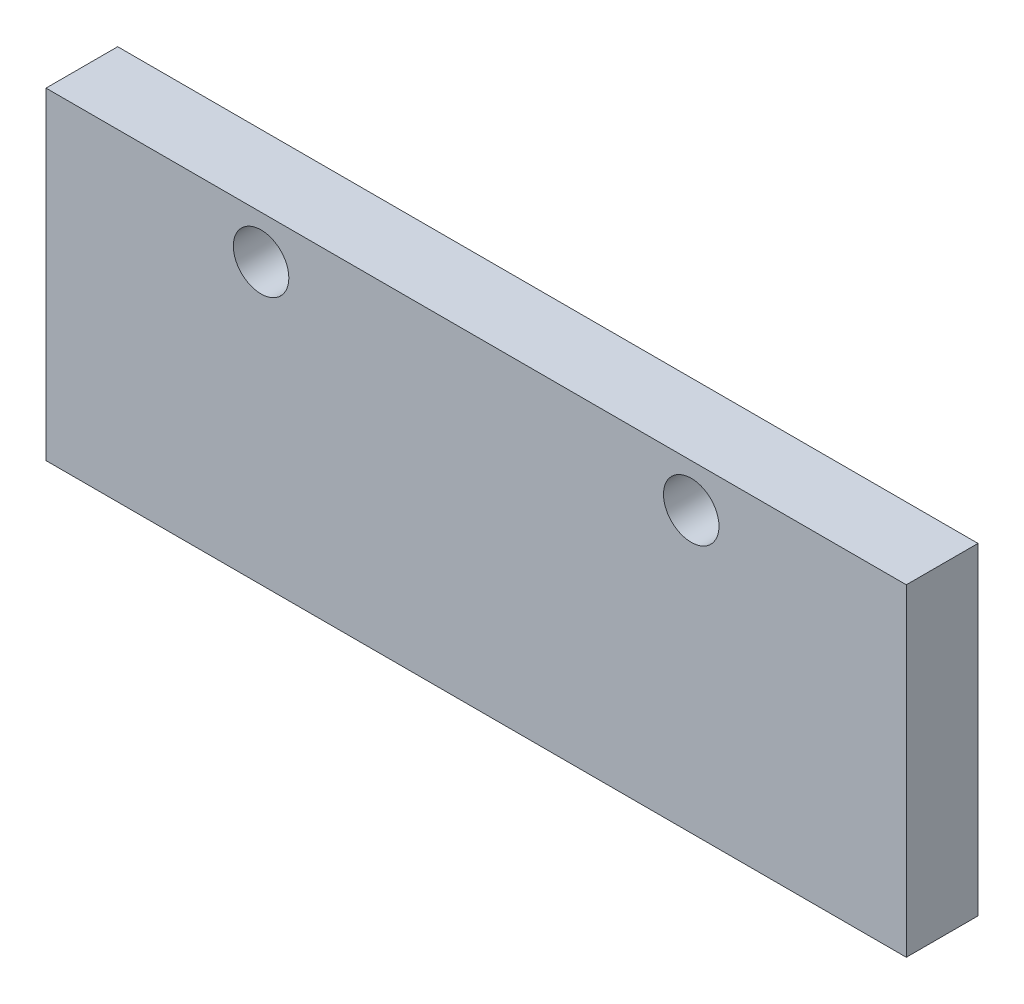
from build123d import *

# Parameters (mm, degrees)
SKETCH1_W                        = 76.2
SKETCH1_H                        = 28.575
BOSS_EXTRUDE1_DEPTH              = 6.35
F_10_0_1935_DIAMETER_HOLE1_D     = 4.9149
F_10_0_1935_DIAMETER_HOLE1_DEPTH = 6.35


with BuildPart() as part:
    # Sketch1 → Boss-Extrude1 (new body)
    with BuildSketch(Plane.XY):
        Rectangle(SKETCH1_W, SKETCH1_H)
    extrude(amount=BOSS_EXTRUDE1_DEPTH)

    # #10 (0.1935) Diameter Hole1
    with Locations(Plane.XY.offset(6.35)):
        with Locations((-19.05, 10.4775), (19.05, 10.4775)):
            Hole(F_10_0_1935_DIAMETER_HOLE1_D / 2, depth=F_10_0_1935_DIAMETER_HOLE1_DEPTH)


solid = part.part
